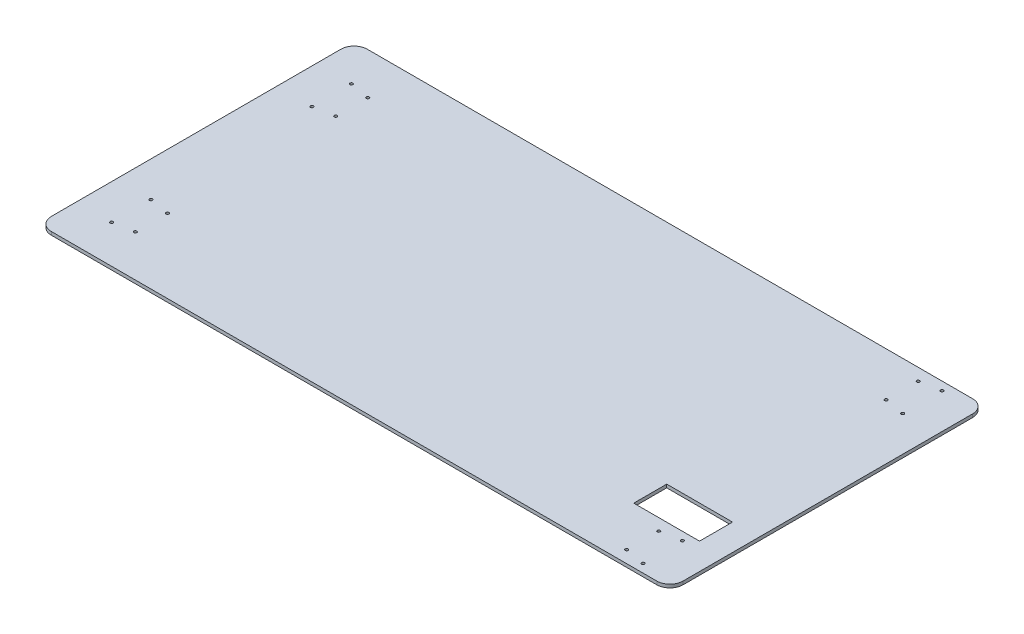
from build123d import *

# Parameters (mm, degrees)
SKETCH2_W           = 1219.2
SKETCH2_H           = 609.6
SKETCH2_R           = 2.794
SKETCH2_W_2         = 127
SKETCH2_H_2         = 63.694904898
BOSS_EXTRUDE1_DEPTH = 6.35
FILLET1_R           = 25.4


with BuildPart() as part:
    # Sketch2 → Boss-Extrude1 (new body)
    with BuildSketch(Plane(origin=(0, 0, 0), x_dir=(1, 0, 0), z_dir=(0, 1, 0))):
        Rectangle(SKETCH2_W, SKETCH2_H)
        with Locations((541.528, 288.544)):
            Circle(SKETCH2_R, mode=Mode.SUBTRACT)
        with Locations((541.528, 212.598)):
            Circle(SKETCH2_R, mode=Mode.SUBTRACT)
        with Locations((502.666, 219.456)):
            Circle(SKETCH2_R, mode=Mode.SUBTRACT)
        with Locations((502.666, 281.432)):
            Circle(SKETCH2_R, mode=Mode.SUBTRACT)
        with Locations((502.666, -281.432)):
            Circle(SKETCH2_R, mode=Mode.SUBTRACT)
        with Locations((502.666, -219.456)):
            Circle(SKETCH2_R, mode=Mode.SUBTRACT)
        with Locations((541.528, -212.598)):
            Circle(SKETCH2_R, mode=Mode.SUBTRACT)
        with Locations((541.528, -288.544)):
            Circle(SKETCH2_R, mode=Mode.SUBTRACT)
        with Locations((-541.528, 155.448)):
            Circle(SKETCH2_R, mode=Mode.SUBTRACT)
        with Locations((-502.666, 224.282)):
            Circle(SKETCH2_R, mode=Mode.SUBTRACT)
        with Locations((-541.528, 231.394)):
            Circle(SKETCH2_R, mode=Mode.SUBTRACT)
        with Locations((-502.666, 162.306)):
            Circle(SKETCH2_R, mode=Mode.SUBTRACT)
        with Locations((-502.666, -162.306)):
            Circle(SKETCH2_R, mode=Mode.SUBTRACT)
        with Locations((-541.528, -231.394)):
            Circle(SKETCH2_R, mode=Mode.SUBTRACT)
        with Locations((-502.666, -224.282)):
            Circle(SKETCH2_R, mode=Mode.SUBTRACT)
        with Locations((-541.528, -155.448)):
            Circle(SKETCH2_R, mode=Mode.SUBTRACT)
        with Locations((495.3, -165.002547551)):
            Rectangle(SKETCH2_W_2, SKETCH2_H_2, mode=Mode.SUBTRACT)
    extrude(amount=BOSS_EXTRUDE1_DEPTH)

    # Fillet1
    fillet1_edges = [part.edges().sort_by_distance(p)[0] for p in [
        (609.6, 3.175, 304.8),
        (-609.6, 3.175, 304.8),
        (-609.6, 3.175, -304.8),
        (609.6, 3.175, -304.8),
    ]]
    fillet(fillet1_edges, radius=FILLET1_R)


solid = part.part
